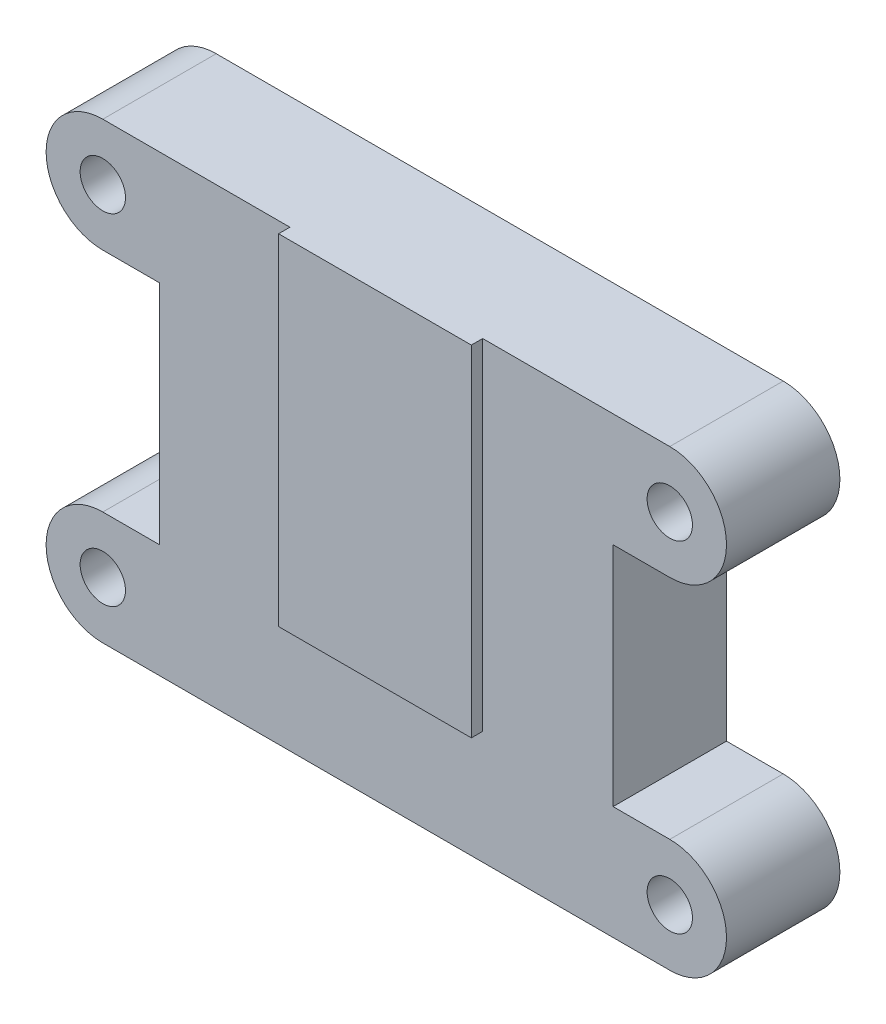
from build123d import *

# Parameters (mm, degrees)
SKETCH1_R           = 2.54
BOSS_EXTRUDE1_DEPTH = 12.7
SKETCH2_W           = 21.59
SKETCH2_H           = 38.1
BOSS_EXTRUDE2_DEPTH = 1.27


with BuildPart() as part:
    # Sketch1 → Boss-Extrude1 (new body)
    with BuildSketch(Plane.XY):
        with BuildLine():
            Line((-31.75, 0), (31.75, 0))
            ThreePointArc((31.75, 0), (38.1, -6.35), (31.75, -12.7))
            Line((31.75, -12.7), (25.4, -12.7))
            Line((25.4, -12.7), (25.4, -38.1))
            Line((25.4, -38.1), (31.75, -38.1))
            ThreePointArc((31.75, -38.1), (38.1, -44.45), (31.75, -50.8))
            Line((31.75, -50.8), (0, -50.8))
            Line((0, -50.8), (-31.75, -50.8))
            ThreePointArc((-31.75, -50.8), (-38.1, -44.45), (-31.75, -38.1))
            Line((-31.75, -38.1), (-25.4, -38.1))
            Line((-25.4, -38.1), (-25.4, -12.7))
            Line((-25.4, -12.7), (-31.75, -12.7))
            ThreePointArc((-31.75, -12.7), (-38.1, -6.35), (-31.75, 0))
        make_face()
        with Locations((-31.75, -6.35)):
            Circle(SKETCH1_R, mode=Mode.SUBTRACT)
        with Locations((31.75, -6.35)):
            Circle(SKETCH1_R, mode=Mode.SUBTRACT)
        with Locations((-31.75, -44.45)):
            Circle(SKETCH1_R, mode=Mode.SUBTRACT)
        with Locations((31.75, -44.45)):
            Circle(SKETCH1_R, mode=Mode.SUBTRACT)
    extrude(amount=BOSS_EXTRUDE1_DEPTH)

    # Sketch2 → Boss-Extrude2 (add)
    with BuildSketch(Plane.XY.offset(12.7)):
        with Locations((0, -19.05)):
            Rectangle(SKETCH2_W, SKETCH2_H)
    extrude(amount=BOSS_EXTRUDE2_DEPTH)


solid = part.part
